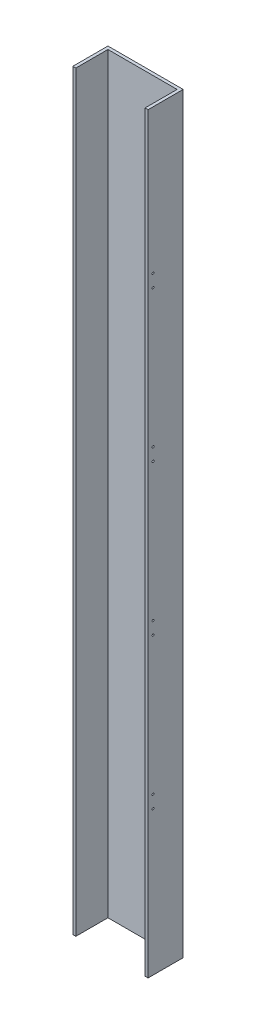
from build123d import *

# Parameters (mm, degrees)
BOSS_EXTRUDE1_DEPTH = 1500
SKETCH2_R           = 2
CUT_EXTRUDE1_DEPTH  = 6
SKETCH3_R           = 2.5
CUT_EXTRUDE2_DEPTH  = 6


with BuildPart() as part:
    # Sketch1 → Boss-Extrude1 (new body)
    with BuildSketch(Plane(origin=(0, 0, 0), x_dir=(1, 0, 0), z_dir=(0, 1, 0))):
        Polygon((-75, 35), (-75, -35), (-69, -35), (-69, 29), (69, 29), (69, -35), (75, -35), (75, 35), align=None)
    extrude(amount=BOSS_EXTRUDE1_DEPTH)

    # Sketch2 → Cut-Extrude1 (cut)
    with BuildSketch(Plane(origin=(75, 0, 0), x_dir=(0, 0, -1), z_dir=(1, 0, 0))):
        with Locations((-25, 312.5)):
            Circle(SKETCH2_R)
        with Locations((-25, 287.5)):
            Circle(SKETCH2_R)
        with Locations((-25, 587.5)):
            Circle(SKETCH2_R)
        with Locations((-25, 612.5)):
            Circle(SKETCH2_R)
        with Locations((-25, 1212.5)):
            Circle(SKETCH2_R)
        with Locations((-25, 1187.5)):
            Circle(SKETCH2_R)
        with Locations((-25, 887.5)):
            Circle(SKETCH2_R)
        with Locations((-25, 912.5)):
            Circle(SKETCH2_R)
    extrude(amount=-CUT_EXTRUDE1_DEPTH, mode=Mode.SUBTRACT)

    # Sketch3 → Cut-Extrude2 (cut)
    with BuildSketch(Plane(origin=(0, 0, -35), x_dir=(-1, 0, 0), z_dir=(0, 0, -1))):
        with Locations((-26.75, 75)):
            Circle(SKETCH3_R)
        with Locations((-26.75, 225)):
            Circle(SKETCH3_R)
        with Locations((-26.75, 375)):
            Circle(SKETCH3_R)
        with Locations((-26.75, 525)):
            Circle(SKETCH3_R)
        with Locations((-26.75, 675)):
            Circle(SKETCH3_R)
        with Locations((-26.75, 825)):
            Circle(SKETCH3_R)
        with Locations((-26.75, 975)):
            Circle(SKETCH3_R)
        with Locations((-26.75, 1125)):
            Circle(SKETCH3_R)
        with Locations((-26.75, 1275)):
            Circle(SKETCH3_R)
        with Locations((-26.75, 1425)):
            Circle(SKETCH3_R)
    extrude(amount=-CUT_EXTRUDE2_DEPTH, mode=Mode.SUBTRACT)


solid = part.part
